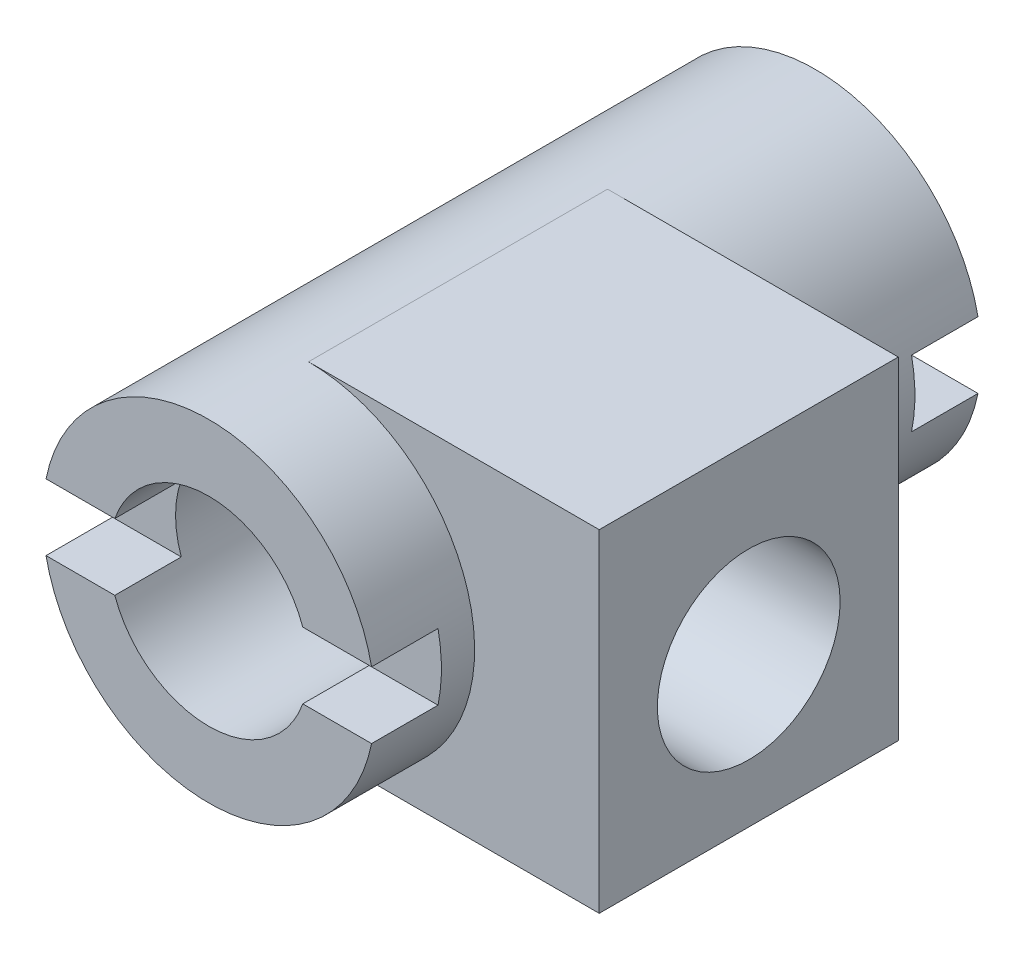
from build123d import *

# Parameters (mm, degrees)
SKETCH1_R           = 20
SKETCH1_R_2         = 12
BOSS_EXTRUDE1_DEPTH = 73
BOSS_EXTRUDE2_REACH = 57
SKETCH2_W           = 36
SKETCH2_H           = 40
SKETCH2_R           = 11
SKETCH4_W           = 48.323472828
SKETCH4_H           = 8
CUT_EXTRUDE1_DEPTH  = 8
SKETCH5_W           = 42.586033238
SKETCH5_H           = 8
CUT_EXTRUDE2_DEPTH  = 8


with BuildPart() as part:
    # Sketch1 → Boss-Extrude1 (new body)
    with BuildSketch(Plane.XY):
        Circle(SKETCH1_R)
        Circle(SKETCH1_R_2, mode=Mode.SUBTRACT)
    extrude(amount=-BOSS_EXTRUDE1_DEPTH)

    # Sketch2 → Boss-Extrude2 (add, up to next)
    with BuildSketch(Plane(origin=(35, 0, 0), x_dir=(0, 0, -1), z_dir=(1, 0, 0)), mode=Mode.PRIVATE) as boss_extrude2_sk1:
        with Locations((30, 0)):
            Rectangle(SKETCH2_W, SKETCH2_H)
        with Locations((30, -2)):
            Circle(SKETCH2_R, mode=Mode.SUBTRACT)
    boss_extrude2_tool1 = extrude(boss_extrude2_sk1.sketch, amount=-BOSS_EXTRUDE2_REACH, mode=Mode.PRIVATE) - part.part
    add(boss_extrude2_tool1.solids().sort_by_distance((35, -19.461855, -30))[0])

    # Sketch4 → Cut-Extrude1 (cut)
    with BuildSketch(Plane.XY):
        with Locations((-1.709156929, 0)):
            Rectangle(SKETCH4_W, SKETCH4_H)
    extrude(amount=-CUT_EXTRUDE1_DEPTH, mode=Mode.SUBTRACT)

    # Sketch5 → Cut-Extrude2 (cut)
    with BuildSketch(Plane(origin=(0, 0, -73), x_dir=(-1, 0, 0), z_dir=(0, 0, -1))):
        Rectangle(SKETCH5_W, SKETCH5_H)
    extrude(amount=-CUT_EXTRUDE2_DEPTH, mode=Mode.SUBTRACT)


solid = part.part
